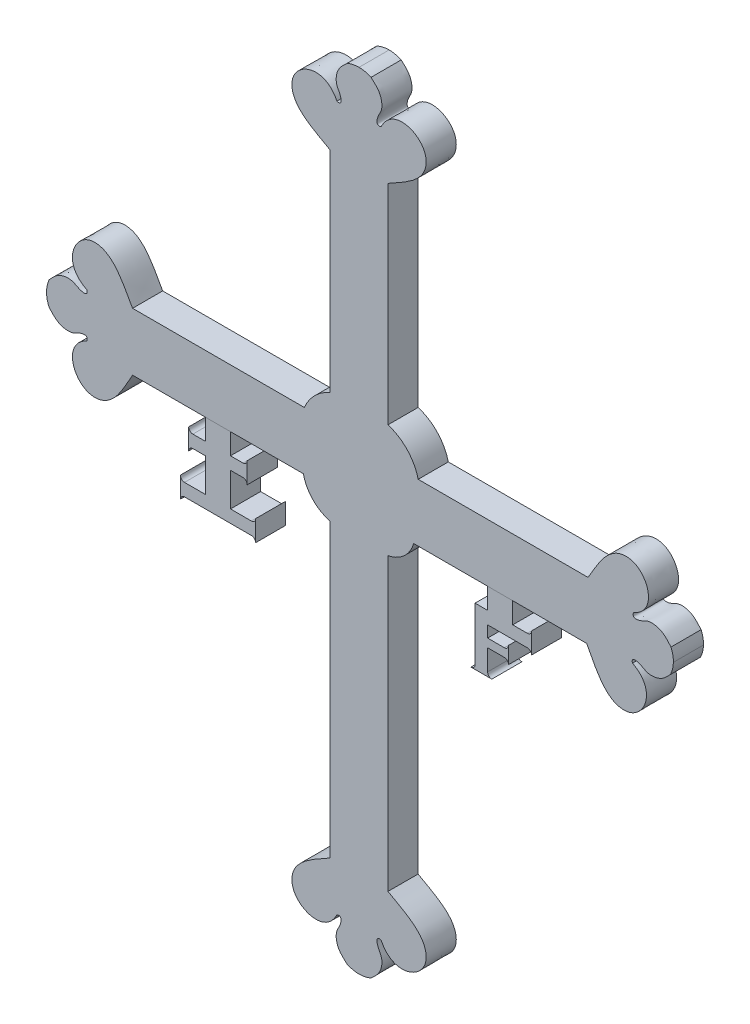
from build123d import *

# Parameters (mm, degrees)
SALIENTE_EXTRUIR1_DEPTH   = 7.2
SALIENTE_EXTRUIR2_DEPTH   = 7.2
SALIENTE_EXTRUIR2_2_DEPTH = 7.2


with BuildPart() as part:
    # Croquis1 → Saliente-Extruir1 (new body)
    with BuildSketch(Plane.XY):
        with BuildLine():
            Line((-250.998392768, 164.74237326), (-250.998392768, 114.510626324))
            ThreePointArc((-250.998392768, 114.510626324), (-254.683172831, 112.027342318), (-257.166456837, 108.342562255))
            Line((-257.166456837, 108.342562255), (-298.225220903, 108.342562255))
            add(Edge.make_bspline(
                [(-298.225220903, 108.342562255), (-299.952370538, 111.216165413), (-302.549555631, 117.445894166), (-312.076352701, 117.598174619), (-314.972141622, 109.533238703), (-309.141169878, 106.713038746)],
                knots=[0, 0, 0, 0, 0.445418482, 0.535607619, 1, 1, 1, 1], degree=3))
            add(Edge.make_bspline(
                [(-309.141169878, 106.713038746), (-308.744080219, 105.469607871), (-310.856602918, 105.73437452), (-312.537952643, 106.98259923), (-314.7694764, 106.918500749), (-316.744226499, 105.931826273), (-317.632471198, 104.845710063), (-318.168915642, 104.303966705)],
                knots=[0, 0, 0, 0, 0.226164914, 0.394336094, 0.620843115, 0.785938977, 1, 1, 1, 1], degree=3))
            add(Edge.make_bspline(
                [(-318.168915642, 104.303966705), (-318.800785942, 102.863597113), (-318.795753938, 101.424178467)],
                knots=[0, 0, 0, 0.504567677, 0.504567677, 0.504567677], degree=2))
            add(Edge.make_bspline(
                [(-318.168915642, 98.54439023), (-318.800785942, 99.984759822), (-318.795753938, 101.424178467)],
                knots=[0, 0, 0, 0.504567677, 0.504567677, 0.504567677], degree=2))
            add(Edge.make_bspline(
                [(-309.141169878, 96.135318189), (-308.744080219, 97.378749064), (-310.856602918, 97.113982415), (-312.537952643, 95.865757705), (-314.7694764, 95.929856186), (-316.744226499, 96.916530662), (-317.632471198, 98.002646872), (-318.168915642, 98.54439023)],
                knots=[0, 0, 0, 0, 0.226164914, 0.394336094, 0.620843115, 0.785938977, 1, 1, 1, 1], degree=3))
            add(Edge.make_bspline(
                [(-298.225220903, 94.50579468), (-299.952370538, 91.632191522), (-302.549555631, 85.402462768), (-312.076352701, 85.250182316), (-314.972141622, 93.315118232), (-309.141169878, 96.135318189)],
                knots=[0, 0, 0, 0, 0.445418482, 0.535607619, 1, 1, 1, 1], degree=3))
            Line((-298.225220903, 94.50579468), (-257.398203773, 94.50579468))
            ThreePointArc((-257.398203773, 94.50579468), (-255.13581818, 90.290242388), (-250.998392768, 87.88795584))
            Line((-250.998392768, 87.88795584), (-250.998392768, 18.13498523))
            add(Edge.make_bspline(
                [(-250.998392768, 18.13498523), (-253.871995926, 16.407835595), (-260.101724679, 13.810650502), (-260.254005132, 4.283853433), (-252.189069216, 1.388064511), (-249.368869259, 7.219036255)],
                knots=[0, 0, 0, 0, 0.445418482, 0.535607619, 1, 1, 1, 1], degree=3))
            add(Edge.make_bspline(
                [(-249.368869259, 7.219036255), (-248.125438384, 7.616125915), (-248.390205033, 5.503603216), (-249.638429743, 3.82225349), (-249.574331262, 1.590729734), (-248.587656786, -0.384020366), (-247.501540576, -1.272265065), (-246.959797218, -1.808709509)],
                knots=[0, 0, 0, 0, 0.226164914, 0.394336094, 0.620843115, 0.785938977, 1, 1, 1, 1], degree=3))
            add(Edge.make_bspline(
                [(-246.959797218, -1.808709509), (-245.519427626, -2.440579809), (-244.08000898, -2.435547805)],
                knots=[0, 0, 0, 0.504567677, 0.504567677, 0.504567677], degree=2))
            add(Edge.make_bspline(
                [(-241.200220743, -1.808709509), (-242.640590335, -2.440579809), (-244.08000898, -2.435547805)],
                knots=[0, 0, 0, 0.504567677, 0.504567677, 0.504567677], degree=2))
            add(Edge.make_bspline(
                [(-238.791148702, 7.219036255), (-240.034579577, 7.616125915), (-239.769812928, 5.503603216), (-238.521588218, 3.82225349), (-238.585686699, 1.590729734), (-239.572361175, -0.384020366), (-240.658477385, -1.272265065), (-241.200220743, -1.808709509)],
                knots=[0, 0, 0, 0, 0.226164914, 0.394336094, 0.620843115, 0.785938977, 1, 1, 1, 1], degree=3))
            add(Edge.make_bspline(
                [(-237.161625193, 18.13498523), (-234.288022035, 16.407835595), (-228.058293281, 13.810650502), (-227.906012829, 4.283853433), (-235.970948745, 1.388064511), (-238.791148702, 7.219036255)],
                knots=[0, 0, 0, 0, 0.445418482, 0.535607619, 1, 1, 1, 1], degree=3))
            Line((-237.161625193, 18.13498523), (-237.161625193, 87.656208903))
            ThreePointArc((-237.161625193, 87.656208903), (-233.299041618, 89.582889089), (-231.012567177, 93.243993162))
            Line((-231.012567177, 93.243993162), (-189.655270784, 93.243993162))
            add(Edge.make_bspline(
                [(-189.655270784, 93.243993162), (-187.995372756, 90.331025688), (-185.543673616, 84.042618729), (-176.022988924, 83.668968171), (-172.940545888, 91.664424989), (-178.704398696, 94.619380164)],
                knots=[0, 0, 0, 0, 0.445418482, 0.535607619, 1, 1, 1, 1], degree=3))
            add(Edge.make_bspline(
                [(-178.704398696, 94.619380164), (-179.07248266, 95.871703897), (-176.966683978, 95.557911857), (-175.314798247, 94.270948236), (-173.082387533, 94.283166807), (-171.085239633, 95.223679827), (-170.171992547, 96.288859074), (-169.623102403, 96.817988658)],
                knots=[0, 0, 0, 0, 0.226164914, 0.394336094, 0.620843115, 0.785938977, 1, 1, 1, 1], degree=3))
            add(Edge.make_bspline(
                [(-169.623102403, 96.817988658), (-168.957927304, 98.24328397), (-168.929504579, 99.682430768)],
                knots=[0, 0, 0, 0.504567677, 0.504567677, 0.504567677], degree=2))
            add(Edge.make_bspline(
                [(-169.489244722, 102.576009437), (-168.891020565, 101.121343669), (-168.929504579, 99.682430768)],
                knots=[0, 0, 0, 0.504567677, 0.504567677, 0.504567677], degree=2))
            add(Edge.make_bspline(
                [(-178.458563061, 105.194243615), (-178.884443904, 103.960377315), (-176.766338398, 104.175975542), (-175.056432962, 105.384787036), (-172.827001659, 105.268843271), (-170.875716144, 104.236540353), (-170.012953671, 103.130073913), (-169.489244722, 102.576009437)],
                knots=[0, 0, 0, 0, 0.226164914, 0.394336094, 0.620843115, 0.785938977, 1, 1, 1, 1], degree=3))
            add(Edge.make_bspline(
                [(-189.333691998, 107.077023344), (-187.540223783, 109.909709831), (-184.798955767, 116.077395006), (-175.271192809, 116.008223088), (-172.563622342, 107.878164849), (-178.458563061, 105.194243615)],
                knots=[0, 0, 0, 0, 0.445418482, 0.535607619, 1, 1, 1, 1], degree=3))
            Line((-189.333691998, 107.077023344), (-229.938576318, 107.077023344))
            ThreePointArc((-229.938576318, 107.077023344), (-232.533499853, 111.86763996), (-237.161625193, 114.74237326))
            Line((-237.161625193, 114.74237326), (-237.161625193, 164.74237326))
            add(Edge.make_bspline(
                [(-237.161625193, 164.74237326), (-234.288022035, 166.469522895), (-228.058293281, 169.066707988), (-227.906012829, 178.593505058), (-235.970948745, 181.489293979), (-238.791148702, 175.658322236)],
                knots=[0, 0, 0, 0, 0.445418482, 0.535607619, 1, 1, 1, 1], degree=3))
            add(Edge.make_bspline(
                [(-238.791148702, 175.658322236), (-240.034579577, 175.261232576), (-239.769812928, 177.373755275), (-238.521588218, 179.055105001), (-238.585686699, 181.286628757), (-239.572361175, 183.261378857), (-240.658477385, 184.149623556), (-241.200220743, 184.686067999)],
                knots=[0, 0, 0, 0, 0.226164914, 0.394336094, 0.620843115, 0.785938977, 1, 1, 1, 1], degree=3))
            add(Edge.make_bspline(
                [(-241.200220743, 184.686067999), (-242.640590335, 185.317938299), (-244.08000898, 185.312906295)],
                knots=[0, 0, 0, 0.504567677, 0.504567677, 0.504567677], degree=2))
            add(Edge.make_bspline(
                [(-246.959797218, 184.686067999), (-245.519427626, 185.317938299), (-244.08000898, 185.312906295)],
                knots=[0, 0, 0, 0.504567677, 0.504567677, 0.504567677], degree=2))
            add(Edge.make_bspline(
                [(-249.368869259, 175.658322236), (-248.125438384, 175.261232576), (-248.390205033, 177.373755275), (-249.638429743, 179.055105001), (-249.574331262, 181.286628757), (-248.587656786, 183.261378857), (-247.501540576, 184.149623556), (-246.959797218, 184.686067999)],
                knots=[0, 0, 0, 0, 0.226164914, 0.394336094, 0.620843115, 0.785938977, 1, 1, 1, 1], degree=3))
            add(Edge.make_bspline(
                [(-250.998392768, 164.74237326), (-253.871995926, 166.469522895), (-260.101724679, 169.066707988), (-260.254005132, 178.593505058), (-252.189069216, 181.489293979), (-249.368869259, 175.658322236)],
                knots=[0, 0, 0, 0, 0.445418482, 0.535607619, 1, 1, 1, 1], degree=3))
        make_face()
    extrude(amount=SALIENTE_EXTRUIR1_DEPTH)


with BuildPart() as body_2:
    # Croquis2 → Saliente-Extruir2 (new body)
    with BuildSketch(Plane.XY.offset(7.2)):
        with BuildLine():
            Line((-274.811712338, 94.50579468), (-280.811712338, 94.50579468))
            Line((-280.811712338, 94.50579468), (-280.811712338, 89.50579468))
            Line((-280.811712338, 89.50579468), (-283.811712338, 89.50579468))
            ThreePointArc((-283.811712338, 89.50579468), (-284.518819119, 89.798687898), (-284.811712338, 90.50579468))
            Line((-284.811712338, 90.50579468), (-284.811712338, 85.50579468))
            ThreePointArc((-284.811712338, 85.50579468), (-284.518819119, 86.212901461), (-283.811712338, 86.50579468))
            Line((-283.811712338, 86.50579468), (-280.811712338, 86.50579468))
            Line((-280.811712338, 86.50579468), (-280.811712338, 78.50579468))
            Line((-280.811712338, 78.50579468), (-285.811712338, 78.50579468))
            ThreePointArc((-285.811712338, 78.50579468), (-286.518819119, 78.798687898), (-286.811712338, 79.50579468))
            Line((-286.811712338, 79.50579468), (-286.811712338, 74.50579468))
            ThreePointArc((-286.811712338, 74.50579468), (-286.518819119, 75.212901461), (-285.811712338, 75.50579468))
            Line((-285.811712338, 75.50579468), (-269.811712338, 75.50579468))
            ThreePointArc((-269.811712338, 75.50579468), (-269.104605557, 75.212901461), (-268.811712338, 74.50579468))
            Line((-268.811712338, 74.50579468), (-268.811712338, 79.50579468))
            ThreePointArc((-268.811712338, 79.50579468), (-269.104605557, 78.798687898), (-269.811712338, 78.50579468))
            Line((-269.811712338, 78.50579468), (-274.811712338, 78.50579468))
            Line((-274.811712338, 78.50579468), (-274.811712338, 86.50579468))
            Line((-274.811712338, 86.50579468), (-271.811712338, 86.50579468))
            ThreePointArc((-271.811712338, 86.50579468), (-271.104605557, 86.212901461), (-270.811712338, 85.50579468))
            Line((-270.811712338, 85.50579468), (-270.811712338, 90.50579468))
            ThreePointArc((-270.811712338, 90.50579468), (-271.104605557, 89.798687898), (-271.811712338, 89.50579468))
            Line((-271.811712338, 89.50579468), (-274.811712338, 89.50579468))
            Line((-274.811712338, 89.50579468), (-274.811712338, 94.50579468))
        make_face()
    extrude(amount=-SALIENTE_EXTRUIR2_DEPTH)


with BuildPart() as body_3:
    # Croquis2 → Saliente-Extruir2 2 (new body)
    with BuildSketch(Plane.XY.offset(7.2)):
        with BuildLine():
            Line((-213.33391898, 93.243993162), (-213.33391898, 88.243993162))
            Line((-213.33391898, 88.243993162), (-216.33391898, 88.243993162))
            Line((-216.33391898, 88.243993162), (-216.33391898, 75.50579468))
            ThreePointArc((-216.33391898, 75.50579468), (-216.626812199, 74.798687898), (-217.33391898, 74.50579468))
            Line((-217.33391898, 74.50579468), (-212.33391898, 74.50579468))
            ThreePointArc((-212.33391898, 74.50579468), (-213.041025762, 74.798687898), (-213.33391898, 75.50579468))
            Line((-213.33391898, 75.50579468), (-213.33391898, 80.50579468))
            Line((-213.33391898, 80.50579468), (-209.33391898, 80.50579468))
            ThreePointArc((-209.33391898, 80.50579468), (-208.626812199, 80.212901461), (-208.33391898, 79.50579468))
            Line((-208.33391898, 79.50579468), (-208.33391898, 83.50579468))
            ThreePointArc((-208.33391898, 83.50579468), (-208.626812199, 82.798687898), (-209.33391898, 82.50579468))
            Line((-209.33391898, 82.50579468), (-213.33391898, 82.50579468))
            Line((-213.33391898, 82.50579468), (-213.33391898, 83.50579468))
            Line((-213.33391898, 83.50579468), (-213.33391898, 85.24579468))
            Line((-213.33391898, 85.24579468), (-203.834819739, 85.24579468))
            ThreePointArc((-203.834819739, 85.24579468), (-203.127075739, 84.952637516), (-202.833918575, 84.244893515))
            Line((-202.833918575, 84.244893515), (-202.833918575, 89.244893515))
            ThreePointArc((-202.833918575, 89.244893515), (-203.127075739, 88.537149515), (-203.834819739, 88.243992351))
            Line((-203.834819739, 88.243992351), (-207.334819739, 88.243992351))
            Line((-207.334819739, 88.243992351), (-207.334819739, 93.243993162))
            Line((-207.334819739, 93.243993162), (-213.33391898, 93.243993162))
        make_face()
    extrude(amount=-SALIENTE_EXTRUIR2_2_DEPTH)


solid = Compound([part.part, body_2.part, body_3.part])
